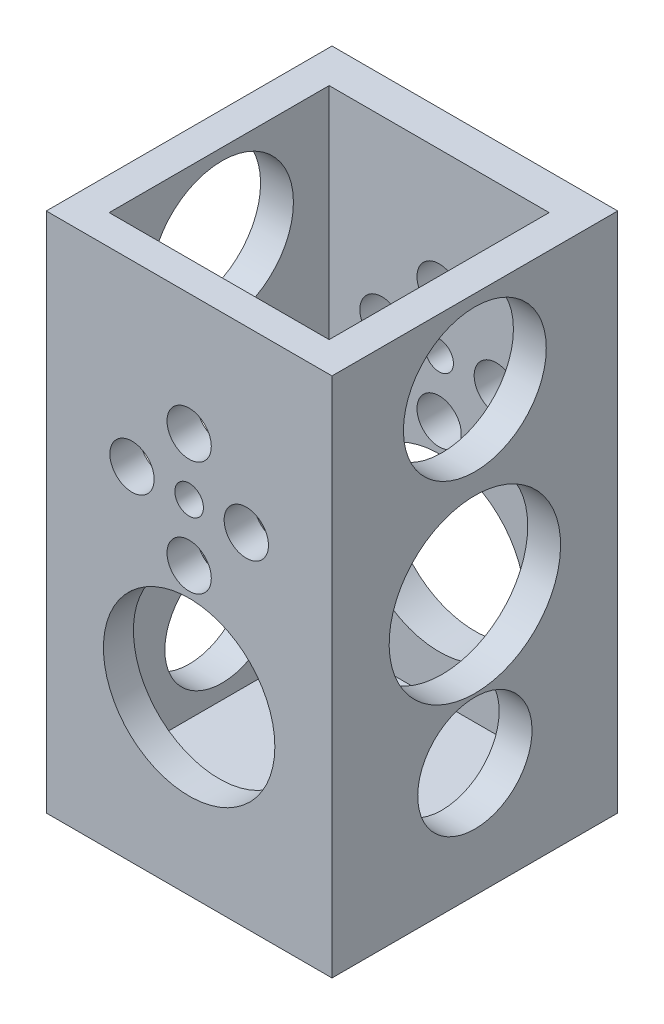
from build123d import *

# Parameters (mm, degrees)
SKETCH_1_R          = 1
SKETCH_1_R_2        = 1.55
SKETCH_1_R_3        = 6
EXTRUDE_1_DEPTH     = 20
CUT_EXTRUDE_1_DEPTH = 33.5
CUT_EXTRUDE_2_DEPTH = 21


with BuildPart() as part:
    # 草图1 → 凸台-拉伸1 (new body)
    with BuildSketch(Plane.XY):
        Polygon((10, 0), (10, 12.5), (0, 12.5), (-10, 12.5), (-10, -24), (10, -24), align=None)
        Circle(SKETCH_1_R, mode=Mode.SUBTRACT)
        with Locations((0, 4)):
            Circle(SKETCH_1_R_2, mode=Mode.SUBTRACT)
        with Locations((4, 0)):
            Circle(SKETCH_1_R_2, mode=Mode.SUBTRACT)
        with Locations((0, -4)):
            Circle(SKETCH_1_R_2, mode=Mode.SUBTRACT)
        with Locations((-4, 0)):
            Circle(SKETCH_1_R_2, mode=Mode.SUBTRACT)
        with Locations((0, -11.97364961)):
            Circle(SKETCH_1_R_3, mode=Mode.SUBTRACT)
    extrude(amount=EXTRUDE_1_DEPTH)

    # 草图2 → 切除-拉伸1 (cut)
    with BuildSketch(Plane(origin=(0, 12.5, 0), x_dir=(1, 0, 0), z_dir=(0, 1, 0))):
        Polygon((-7.7, -10.2), (-7.7, -2.5), (0, -2.5), (7.7, -2.5), (7.7, -17.9), (0, -17.9), (-7.7, -17.9), align=None)
    extrude(amount=-CUT_EXTRUDE_1_DEPTH, mode=Mode.SUBTRACT)

    # 草图3 → 切除-拉伸2 (cut, through all)
    with BuildSketch(Plane.ZY.offset(10)):
        with BuildLine():
            ThreePointArc((16, -5.75), (14.242640687, -1.507359313), (10, 0.25))
            Line((10, 0.25), (10, -11.75))
            ThreePointArc((10, -11.75), (14.242640687, -9.992640687), (16, -5.75))
        make_face()
        with BuildLine():
            Line((10, -11.75), (10, 0.25))
            ThreePointArc((10, 0.25), (4, -5.75), (10, -11.75))
        make_face()
        with BuildLine():
            ThreePointArc((15, 6.688097559), (13.535533906, 10.223631465), (10, 11.688097559))
            Line((10, 11.688097559), (10, 1.688097559))
            ThreePointArc((10, 1.688097559), (13.535533906, 3.152563653), (15, 6.688097559))
        make_face()
        with BuildLine():
            Line((10, 1.688097559), (10, 11.688097559))
            ThreePointArc((10, 11.688097559), (5, 6.688097559), (10, 1.688097559))
        make_face()
        with BuildLine():
            ThreePointArc((14, -15.973088327), (12.828427125, -13.144661202), (10, -11.973088327))
            Line((10, -11.973088327), (10, -19.973088327))
            ThreePointArc((10, -19.973088327), (12.828427125, -18.801515451), (14, -15.973088327))
        make_face()
        with BuildLine():
            Line((10, -19.973088327), (10, -11.973088327))
            ThreePointArc((10, -11.973088327), (6, -15.973088327), (10, -19.973088327))
        make_face()
    extrude(amount=-CUT_EXTRUDE_2_DEPTH, mode=Mode.SUBTRACT)


solid = part.part
